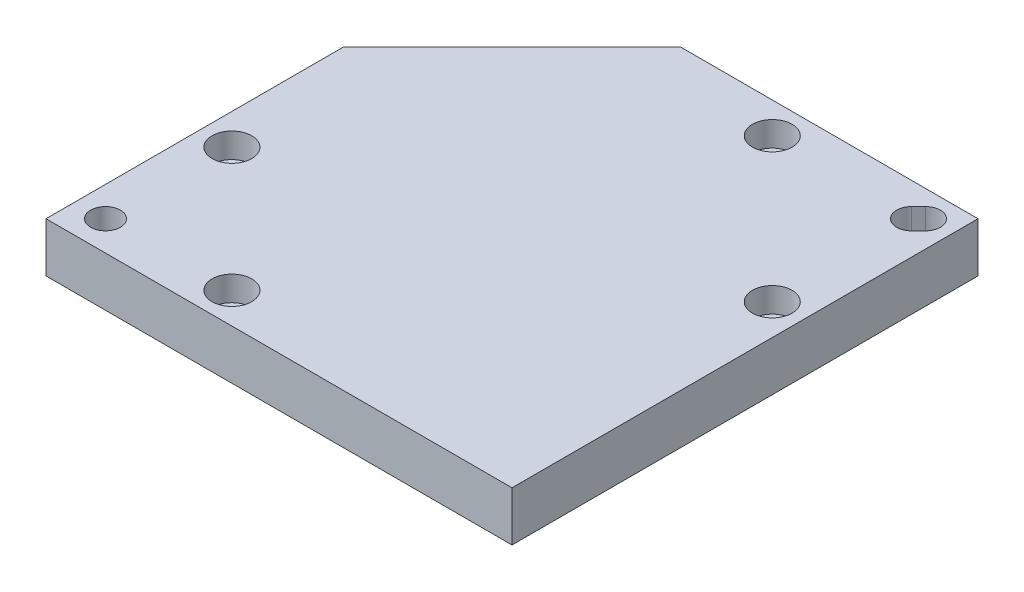
from build123d import *

# Parameters (mm, degrees)
BOSS_EXTRUDE1_DEPTH = 10
SKETCH3_R           = 2.25
SKETCH3_R_2         = 3
CUT_EXTRUDE1_DEPTH  = 10
SKETCH5_R           = 4
CUT_EXTRUDE2_DEPTH  = 5


with BuildPart() as part:
    # Sketch2 → Boss-Extrude1 (new body)
    with BuildSketch(Plane(origin=(0, 0, 0), x_dir=(1, 0, 0), z_dir=(0, 1, 0))):
        Polygon((0, -34), (34, 0), (94, 0), (94, -94), (0, -94), align=None)
    extrude(amount=BOSS_EXTRUDE1_DEPTH)

    # Sketch3 → Cut-Extrude1 (cut)
    with BuildSketch(Plane(origin=(0, 10, 0), x_dir=(1, 0, 0), z_dir=(0, 1, 0))):
        with Locations((58.75, -6.25)):
            Circle(SKETCH3_R)
        with Locations((87.75, -35.25)):
            Circle(SKETCH3_R)
        with Locations((6.25, -62.75)):
            Circle(SKETCH3_R)
        with Locations((31.25, -87.75)):
            Circle(SKETCH3_R)
        with Locations((6, -88)):
            Circle(SKETCH3_R_2)
        with BuildLine():
            Line((90.828427125, -7.414213562), (89.414213562, -8.828427125))
            ThreePointArc((89.414213562, -8.828427125), (85.171572875, -8.828427125), (85.171572875, -4.585786438))
            Line((85.171572875, -4.585786438), (86.585786438, -3.171572875))
            ThreePointArc((86.585786438, -3.171572875), (90.828427125, -3.171572875), (90.828427125, -7.414213562))
        make_face()
    extrude(amount=-CUT_EXTRUDE1_DEPTH, mode=Mode.SUBTRACT)

    # Sketch5 → Cut-Extrude2 (cut)
    with BuildSketch(Plane(origin=(0, 10, 0), x_dir=(1, 0, 0), z_dir=(0, 1, 0))):
        with Locations((58.75, -6.25)):
            Circle(SKETCH5_R)
        with Locations((87.75, -35.25)):
            Circle(SKETCH5_R)
        with Locations((6.25, -62.75)):
            Circle(SKETCH5_R)
        with Locations((31.25, -87.75)):
            Circle(SKETCH5_R)
    extrude(amount=-CUT_EXTRUDE2_DEPTH, mode=Mode.SUBTRACT)


solid = part.part
